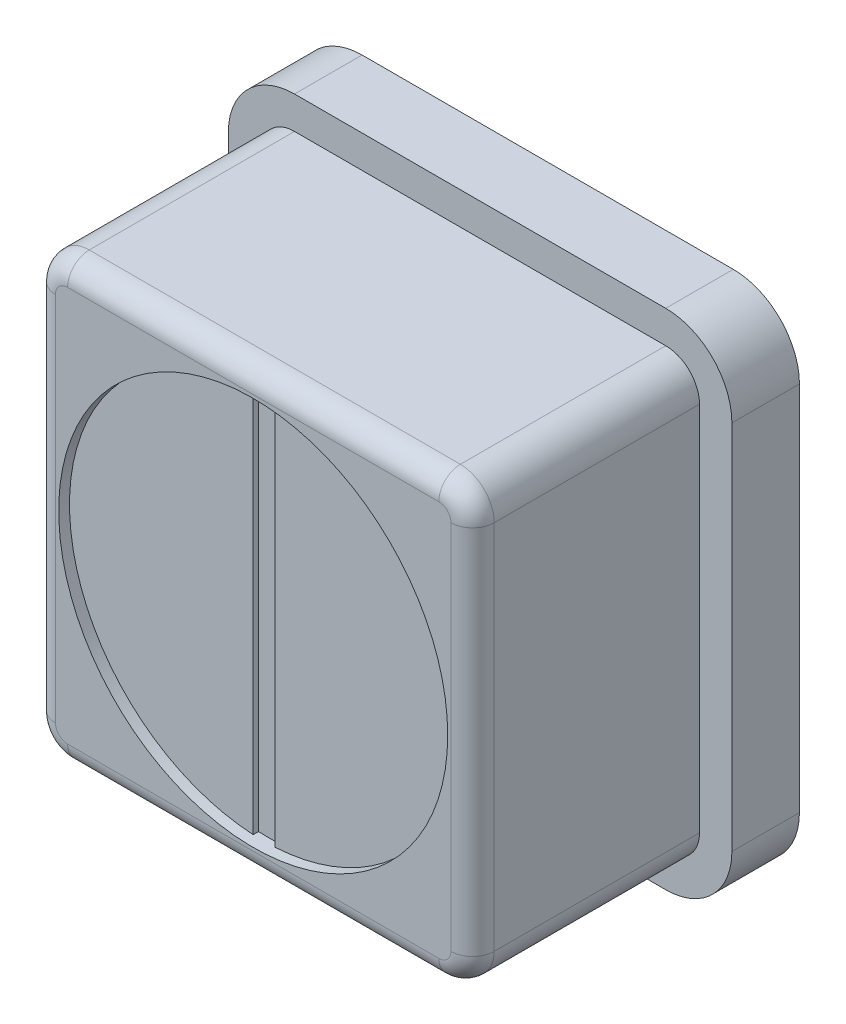
from build123d import *

# Parameters (mm, degrees)
BOSS_EXTRUDE1_DEPTH              = 5.334
FILLET1_R                        = 0.508
SKETCH2_R                        = 4.572
CUT_EXTRUDE1_DEPTH               = 0.254
CUT_EXTRUDE2_DEPTH               = 0.127
BOSS_EXTRUDE2_DEPTH              = 1.5875
F_56_0_0465_DIAMETER_HOLE1_D     = 1.1811
F_56_0_0465_DIAMETER_HOLE1_DEPTH = 5.08


with BuildPart() as part:
    # Sketch1 → Boss-Extrude1 (new body)
    with BuildSketch(Plane.XY):
        with BuildLine():
            Line((4.362446893, 5.156199954), (-4.362446893, 5.156199954))
            ThreePointArc((-4.362446893, 5.156199954), (-4.923713797, 4.923718126), (-5.156199954, 4.362453015))
            Line((-5.156199954, 4.362453015), (-5.156199954, -4.362453015))
            ThreePointArc((-5.156199954, -4.362453015), (-4.923714856, -4.923717067), (-4.362449887, -5.156199954))
            Line((-4.362449887, -5.156199954), (4.362449887, -5.156199954))
            ThreePointArc((4.362449887, -5.156199954), (4.92371702, -4.923714903), (5.156199954, -4.362446893))
            Line((5.156199954, -4.362446893), (5.156199954, 4.362446893))
            ThreePointArc((5.156199954, 4.362446893), (4.923715961, 4.923715962), (4.362446893, 5.156199954))
        make_face()
    extrude(amount=-BOSS_EXTRUDE1_DEPTH)

    # Fillet1
    fillet1_edges = [part.edges().sort_by_distance(p)[0] for p in [
        (0, 5.156199954, 0),
        (4.923715961, 4.923715962, 0),
        (5.156199954, 0, 0),
        (4.92371702, -4.923714903, 0),
        (0, -5.156199954, 0),
        (-4.923714856, -4.923717067, 0),
        (-5.156199954, 0, 0),
        (-4.923713797, 4.923718126, 0),
    ]]
    fillet(fillet1_edges, radius=FILLET1_R)

    # Sketch2 → Cut-Extrude1 (cut)
    with BuildSketch(Plane.XY):
        Circle(SKETCH2_R)
    extrude(amount=-CUT_EXTRUDE1_DEPTH, mode=Mode.SUBTRACT)

    # Sketch3 → Cut-Extrude2 (cut)
    with BuildSketch(Plane.XY.offset(-0.254)):
        with BuildLine():
            Line((-0.254, 4.564938992), (-0.254, -4.564938992))
            ThreePointArc((-0.254, -4.564938992), (0, -4.572), (0.254, -4.564938992))
            Line((0.254, -4.564938992), (0.254, 4.564938992))
            ThreePointArc((0.254, 4.564938992), (0, 4.572), (-0.254, 4.564938992))
        make_face()
    extrude(amount=-CUT_EXTRUDE2_DEPTH, mode=Mode.SUBTRACT)

    # Sketch4 → Boss-Extrude2 (add)
    with BuildSketch(Plane(origin=(0, 0, -5.334), x_dir=(-1, 0, 0), z_dir=(0, 0, -1))):
        with BuildLine():
            Line((-5.918199954, 4.362443955), (-5.918199954, -4.362446893))
            ThreePointArc((-5.918199954, -4.362446893), (-5.462532364, -5.462530293), (-4.362449822, -5.918199954))
            Line((-4.362449822, -5.918199954), (4.362449887, -5.918199954))
            ThreePointArc((4.362449887, -5.918199954), (5.462529184, -5.462533474), (5.918199954, -4.362455953))
            Line((5.918199954, -4.362455953), (5.918199954, 4.362453015))
            ThreePointArc((5.918199954, 4.362453015), (5.462528126, 5.462534532), (4.362443955, 5.918199954))
            Line((4.362443955, 5.918199954), (-4.362443955, 5.918199954))
            ThreePointArc((-4.362443955, 5.918199954), (-5.462531329, 5.462531329), (-5.918199954, 4.362443955))
        make_face()
    extrude(amount=BOSS_EXTRUDE2_DEPTH)

    # #56 (0.0465) Diameter Hole1
    with Locations(Plane(origin=(0, 0, -6.9215), x_dir=(-1, 0, 0), z_dir=(0, 0, -1))):
        with Locations((0, 0)):
            Hole(F_56_0_0465_DIAMETER_HOLE1_D / 2, depth=F_56_0_0465_DIAMETER_HOLE1_DEPTH)


solid = part.part
